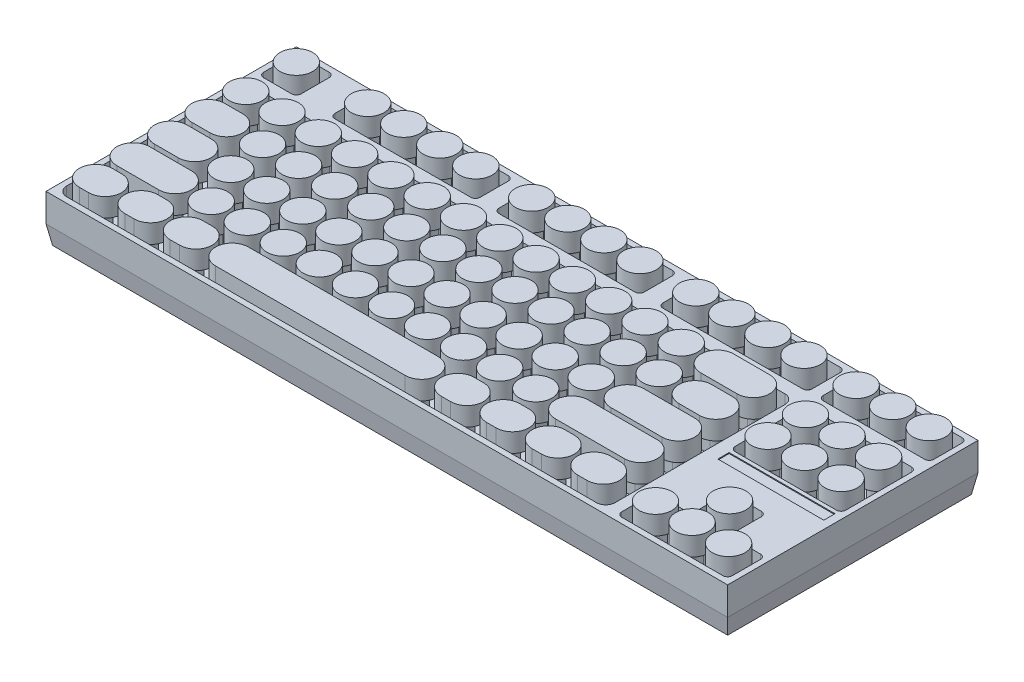
from build123d import *

# Parameters (mm, degrees)
SKETCH1_W            = 360
SKETCH1_H            = 130
BOSS_EXTRUDE1_DEPTH  = 10
DRAFT1_ANGLE         = 10
SKETCH2_W            = 363.526539614
SKETCH2_H            = 133.526539614
BOSS_EXTRUDE2_DEPTH  = 15
SKETCH3_R            = 4.5
BOSS_EXTRUDE3_DEPTH  = 15
BOSS_EXTRUDE5_START  = -4
SKETCH4_R            = 8.75
BOSS_EXTRUDE5_DEPTH  = 10
SKETCH5_W            = 56.5
SKETCH5_H            = 6
CUT_EXTRUDE1_DEPTH   = 0.5
SKETCH6_W            = 20
SKETCH6_H            = 20
CUT_EXTRUDE2_DEPTH   = 3
BOSS_EXTRUDE6_DEPTH  = 1
CUT_EXTRUDE3_DEPTH   = 20
CUT_EXTRUDE4_START   = -270
CUT_EXTRUDE4_DEPTH   = 20
BOSS_EXTRUDE7_DEPTH  = 20
BOSS_EXTRUDE8_START  = -290
BOSS_EXTRUDE8_DEPTH  = 20
BOSS_EXTRUDE12_DEPTH = 20
BOSS_EXTRUDE13_START = -290
BOSS_EXTRUDE13_DEPTH = 20


with BuildPart() as part:
    # Sketch1 → Boss-Extrude1 (new body)
    with BuildSketch(Plane(origin=(0, 0, 0), x_dir=(1, 0, 0), z_dir=(0, 1, 0))):
        Rectangle(SKETCH1_W, SKETCH1_H)
    extrude(amount=BOSS_EXTRUDE1_DEPTH)

    # Draft1
    draft1_faces = [part.faces().sort_by_distance(p)[0] for p in [
        (180, 5, 0),
        (0, 5, -65),
        (-180, 5, 0),
        (0, 5, 65),
    ]]
    draft(draft1_faces, Plane(origin=(0, 0, 0), x_dir=(0, 0, -1), z_dir=(0, -1, 0)), DRAFT1_ANGLE)

    # Sketch2 → Boss-Extrude2 (add)
    with BuildSketch(Plane(origin=(0, 10, 0), x_dir=(1, 0, 0), z_dir=(0, 1, 0))):
        Rectangle(SKETCH2_W, SKETCH2_H)
        with BuildLine():
            Line((111.263269807, 63.763269807), (36.766730193, 63.763269807))
            ThreePointArc((36.766730193, 63.763269807), (34.99896324, 63.03103676), (34.266730193, 61.263269807))
            Line((34.266730193, 61.263269807), (34.266730193, 46.263269807))
            ThreePointArc((34.266730193, 46.263269807), (34.99896324, 44.495502854), (36.766730193, 43.763269807))
            Line((36.766730193, 43.763269807), (111.263269807, 43.763269807))
            ThreePointArc((111.263269807, 43.763269807), (113.03103676, 44.495502854), (113.763269807, 46.263269807))
            Line((113.763269807, 46.263269807), (113.763269807, 61.263269807))
            ThreePointArc((113.763269807, 61.263269807), (113.03103676, 63.03103676), (111.263269807, 63.763269807))
        make_face(mode=Mode.SUBTRACT)
        with BuildLine():
            Line((176.263269807, 63.763269807), (122.263269807, 63.763269807))
            ThreePointArc((122.263269807, 63.763269807), (120.495502854, 63.03103676), (119.763269807, 61.263269807))
            Line((119.763269807, 61.263269807), (119.763269807, 46.263269807))
            ThreePointArc((119.763269807, 46.263269807), (120.495502854, 44.495502854), (122.263269807, 43.763269807))
            Line((122.263269807, 43.763269807), (176.263269807, 43.763269807))
            ThreePointArc((176.263269807, 43.763269807), (178.03103676, 44.495502854), (178.763269807, 46.263269807))
            Line((178.763269807, 46.263269807), (178.763269807, 61.263269807))
            ThreePointArc((178.763269807, 61.263269807), (178.03103676, 63.03103676), (176.263269807, 63.763269807))
        make_face(mode=Mode.SUBTRACT)
        with BuildLine():
            Line((178.763269807, -46.263269807), (178.763269807, -61.263269807))
            ThreePointArc((178.763269807, -61.263269807), (178.03103676, -63.03103676), (176.263269807, -63.763269807))
            Line((176.263269807, -63.763269807), (122.263269807, -63.763269807))
            ThreePointArc((122.263269807, -63.763269807), (120.495502854, -63.03103676), (119.763269807, -61.263269807))
            Line((119.763269807, -61.263269807), (119.763269807, -46.263269807))
            ThreePointArc((119.763269807, -46.263269807), (120.495502854, -44.495502854), (122.263269807, -43.763269807))
            Line((122.263269807, -43.763269807), (136.763269807, -43.763269807))
            ThreePointArc((136.763269807, -43.763269807), (138.53103676, -43.03103676), (139.263269807, -41.263269807))
            Line((139.263269807, -41.263269807), (139.263269807, -26.263269807))
            ThreePointArc((139.263269807, -26.263269807), (139.995502854, -24.495502854), (141.763269807, -23.763269807))
            Line((141.763269807, -23.763269807), (156.763269807, -23.763269807))
            ThreePointArc((156.763269807, -23.763269807), (158.53103676, -24.495502854), (159.263269807, -26.263269807))
            Line((159.263269807, -26.263269807), (159.263269807, -41.263269807))
            ThreePointArc((159.263269807, -41.263269807), (159.995502854, -43.03103676), (161.763269807, -43.763269807))
            Line((161.763269807, -43.763269807), (176.263269807, -43.763269807))
            ThreePointArc((176.263269807, -43.763269807), (178.03103676, -44.495502854), (178.763269807, -46.263269807))
        make_face(mode=Mode.SUBTRACT)
        with BuildLine():
            Line((-178.763269807, 31.763269807), (-178.763269807, -58.763269807))
            ThreePointArc((-178.763269807, -58.763269807), (-177.298803713, -62.298803713), (-173.763269807, -63.763269807))
            Line((-173.763269807, -63.763269807), (108.763269807, -63.763269807))
            ThreePointArc((108.763269807, -63.763269807), (112.298803713, -62.298803713), (113.763269807, -58.763269807))
            Line((113.763269807, -58.763269807), (113.763269807, 31.763269807))
            ThreePointArc((113.763269807, 31.763269807), (112.298803713, 35.298803713), (108.763269807, 36.763269807))
            Line((108.763269807, 36.763269807), (-173.763269807, 36.763269807))
            ThreePointArc((-173.763269807, 36.763269807), (-177.298803713, 35.298803713), (-178.763269807, 31.763269807))
        make_face(mode=Mode.SUBTRACT)
        with BuildLine():
            Line((-161.263269807, 63.763269807), (-176.263269807, 63.763269807))
            ThreePointArc((-176.263269807, 63.763269807), (-178.03103676, 63.03103676), (-178.763269807, 61.263269807))
            Line((-178.763269807, 61.263269807), (-178.763269807, 46.263269807))
            ThreePointArc((-178.763269807, 46.263269807), (-178.03103676, 44.495502854), (-176.263269807, 43.763269807))
            Line((-176.263269807, 43.763269807), (-161.263269807, 43.763269807))
            ThreePointArc((-161.263269807, 43.763269807), (-159.495502854, 44.495502854), (-158.763269807, 46.263269807))
            Line((-158.763269807, 46.263269807), (-158.763269807, 61.263269807))
            ThreePointArc((-158.763269807, 61.263269807), (-159.495502854, 63.03103676), (-161.263269807, 63.763269807))
        make_face(mode=Mode.SUBTRACT)
        with BuildLine():
            Line((-65.733269807, 63.763269807), (-138.233269807, 63.763269807))
            ThreePointArc((-138.233269807, 63.763269807), (-140.00103676, 63.03103676), (-140.733269807, 61.263269807))
            Line((-140.733269807, 61.263269807), (-140.733269807, 46.263269807))
            ThreePointArc((-140.733269807, 46.263269807), (-140.00103676, 44.495502854), (-138.233269807, 43.763269807))
            Line((-138.233269807, 43.763269807), (-65.733269807, 43.763269807))
            ThreePointArc((-65.733269807, 43.763269807), (-63.965502854, 44.495502854), (-63.233269807, 46.263269807))
            Line((-63.233269807, 46.263269807), (-63.233269807, 61.263269807))
            ThreePointArc((-63.233269807, 61.263269807), (-63.965502854, 63.03103676), (-65.733269807, 63.763269807))
        make_face(mode=Mode.SUBTRACT)
        with BuildLine():
            Line((21.766730193, 63.763269807), (-50.733269807, 63.763269807))
            ThreePointArc((-50.733269807, 63.763269807), (-52.50103676, 63.03103676), (-53.233269807, 61.263269807))
            Line((-53.233269807, 61.263269807), (-53.233269807, 46.263269807))
            ThreePointArc((-53.233269807, 46.263269807), (-52.50103676, 44.495502854), (-50.733269807, 43.763269807))
            Line((-50.733269807, 43.763269807), (21.766730193, 43.763269807))
            ThreePointArc((21.766730193, 43.763269807), (23.534497146, 44.495502854), (24.266730193, 46.263269807))
            Line((24.266730193, 46.263269807), (24.266730193, 61.263269807))
            ThreePointArc((24.266730193, 61.263269807), (23.534497146, 63.03103676), (21.766730193, 63.763269807))
        make_face(mode=Mode.SUBTRACT)
        with BuildLine():
            Line((176.263269807, 36.763269807), (122.263269807, 36.763269807))
            ThreePointArc((122.263269807, 36.763269807), (120.495502854, 36.03103676), (119.763269807, 34.263269807))
            Line((119.763269807, 34.263269807), (119.763269807, -0.736730193))
            ThreePointArc((119.763269807, -0.736730193), (120.495502854, -2.504497146), (122.263269807, -3.236730193))
            Line((122.263269807, -3.236730193), (176.263269807, -3.236730193))
            ThreePointArc((176.263269807, -3.236730193), (178.03103676, -2.504497146), (178.763269807, -0.736730193))
            Line((178.763269807, -0.736730193), (178.763269807, 34.263269807))
            ThreePointArc((178.763269807, 34.263269807), (178.03103676, 36.03103676), (176.263269807, 36.763269807))
        make_face(mode=Mode.SUBTRACT)
    extrude(amount=BOSS_EXTRUDE2_DEPTH)

    # Sketch3 → Boss-Extrude3 (add)
    with BuildSketch(Plane(origin=(0, 10, 0), x_dir=(1, 0, 0), z_dir=(0, 1, 0))):
        with Locations((-168.763269807, 53.763269807)):
            Circle(SKETCH3_R)
        with Locations((-130.733269807, 53.763269807)):
            Circle(SKETCH3_R)
        with Locations((-111.508269807, 53.763269807)):
            Circle(SKETCH3_R)
        with Locations((-92.458269807, 53.763269807)):
            Circle(SKETCH3_R)
        with Locations((-73.233269807, 53.763269807)):
            Circle(SKETCH3_R)
        with Locations((-43.233269807, 53.763269807)):
            Circle(SKETCH3_R)
        with Locations((44.266730193, 53.763269807)):
            Circle(SKETCH3_R)
        with Locations((129.763269807, 53.763269807)):
            Circle(SKETCH3_R)
        with Locations((-24.003269807, 53.763269807)):
            Circle(SKETCH3_R)
        with Locations((-4.773269807, 53.763269807)):
            Circle(SKETCH3_R)
        with Locations((14.456730193, 53.763269807)):
            Circle(SKETCH3_R)
        with Locations((63.496730193, 53.763269807)):
            Circle(SKETCH3_R)
        with Locations((82.726730193, 53.763269807)):
            Circle(SKETCH3_R)
        with Locations((101.956730193, 53.763269807)):
            Circle(SKETCH3_R)
        with Locations((168.763269807, 53.763269807)):
            Circle(SKETCH3_R)
        with Locations((149.263269807, 53.763269807)):
            Circle(SKETCH3_R)
        with Locations((129.763269807, 26.763269807)):
            Circle(SKETCH3_R)
        with Locations((149.263269807, 26.763269807)):
            Circle(SKETCH3_R)
        with Locations((168.763269807, 26.763269807)):
            Circle(SKETCH3_R)
        with Locations((168.763269807, 6.763269807)):
            Circle(SKETCH3_R)
        with Locations((149.263269807, 6.763269807)):
            Circle(SKETCH3_R)
        with Locations((129.763269807, 6.763269807)):
            Circle(SKETCH3_R)
        with Locations((63.496730193, 26.763269807)):
            Circle(SKETCH3_R)
        with Locations((44.141730193, 26.763269807)):
            Circle(SKETCH3_R)
        with Locations((24.786730193, 26.763269807)):
            Circle(SKETCH3_R)
        with Locations((5.431730193, 26.763269807)):
            Circle(SKETCH3_R)
        with Locations((-13.923269807, 26.763269807)):
            Circle(SKETCH3_R)
        with Locations((-33.278269807, 26.763269807)):
            Circle(SKETCH3_R)
        with Locations((-52.633269807, 26.763269807)):
            Circle(SKETCH3_R)
        with Locations((-71.988269807, 26.763269807)):
            Circle(SKETCH3_R)
        with Locations((-91.343269807, 26.763269807)):
            Circle(SKETCH3_R)
        with Locations((-110.698269807, 26.763269807)):
            Circle(SKETCH3_R)
        with Locations((-130.053269807, 26.763269807)):
            Circle(SKETCH3_R)
        with Locations((-149.408269807, 26.763269807)):
            Circle(SKETCH3_R)
        with Locations((-168.763269807, 26.763269807)):
            Circle(SKETCH3_R)
        with Locations((129.763269807, -53.236730193)):
            Circle(SKETCH3_R)
        with Locations((149.263269807, -53.236730193)):
            Circle(SKETCH3_R)
        with Locations((168.763269807, -53.236730193)):
            Circle(SKETCH3_R)
        with Locations((149.263269807, -33.236730193)):
            Circle(SKETCH3_R)
        with Locations((-139.793269807, 6.763269807)):
            Circle(SKETCH3_R)
        with Locations((-120.563269807, 6.763269807)):
            Circle(SKETCH3_R)
        with Locations((-101.333269807, 6.763269807)):
            Circle(SKETCH3_R)
        with Locations((-82.103269807, 6.763269807)):
            Circle(SKETCH3_R)
        with Locations((-62.873269807, 6.763269807)):
            Circle(SKETCH3_R)
        with Locations((-43.643269807, 6.763269807)):
            Circle(SKETCH3_R)
        with Locations((-24.413269807, 6.763269807)):
            Circle(SKETCH3_R)
        with Locations((-5.183269807, 6.763269807)):
            Circle(SKETCH3_R)
        with Locations((14.046730193, 6.763269807)):
            Circle(SKETCH3_R)
        with Locations((33.276730193, 6.763269807)):
            Circle(SKETCH3_R)
        with Locations((52.506730193, 6.763269807)):
            Circle(SKETCH3_R)
        with Locations((71.736730193, 6.763269807)):
            Circle(SKETCH3_R)
        with Locations((-136.793269807, -13.236730193)):
            Circle(SKETCH3_R)
        with Locations((-117.563269807, -13.236730193)):
            Circle(SKETCH3_R)
        with Locations((-98.333269807, -13.236730193)):
            Circle(SKETCH3_R)
        with Locations((-79.103269807, -13.236730193)):
            Circle(SKETCH3_R)
        with Locations((-59.873269807, -13.236730193)):
            Circle(SKETCH3_R)
        with Locations((-40.643269807, -13.236730193)):
            Circle(SKETCH3_R)
        with Locations((-21.413269807, -13.236730193)):
            Circle(SKETCH3_R)
        with Locations((-2.183269807, -13.236730193)):
            Circle(SKETCH3_R)
        with Locations((17.046730193, -13.236730193)):
            Circle(SKETCH3_R)
        with Locations((36.276730193, -13.236730193)):
            Circle(SKETCH3_R)
        with Locations((55.506730193, -13.236730193)):
            Circle(SKETCH3_R)
        with Locations((-127.178269807, -33.236730193)):
            Circle(SKETCH3_R)
        with Locations((-107.948269807, -33.236730193)):
            Circle(SKETCH3_R)
        with Locations((-88.718269807, -33.236730193)):
            Circle(SKETCH3_R)
        with Locations((-69.488269807, -33.236730193)):
            Circle(SKETCH3_R)
        with Locations((-50.258269807, -33.236730193)):
            Circle(SKETCH3_R)
        with Locations((-31.028269807, -33.236730193)):
            Circle(SKETCH3_R)
        with Locations((-11.798269807, -33.236730193)):
            Circle(SKETCH3_R)
        with Locations((7.431730193, -33.236730193)):
            Circle(SKETCH3_R)
        with Locations((26.661730193, -33.236730193)):
            Circle(SKETCH3_R)
        with Locations((45.891730193, -33.236730193)):
            Circle(SKETCH3_R)
        with BuildLine():
            Line((-168.763269807, 9.763269807), (-159.023269807, 9.763269807))
            ThreePointArc((-159.023269807, 9.763269807), (-156.023269807, 6.763269807), (-159.023269807, 3.763269807))
            Line((-159.023269807, 3.763269807), (-168.763269807, 3.763269807))
            ThreePointArc((-168.763269807, 3.763269807), (-171.763269807, 6.763269807), (-168.763269807, 9.763269807))
        make_face()
        with BuildLine():
            Line((-168.763269807, -10.236730193), (-156.023269807, -10.236730193))
            ThreePointArc((-156.023269807, -10.236730193), (-153.023269807, -13.236730193), (-156.023269807, -16.236730193))
            Line((-156.023269807, -16.236730193), (-168.763269807, -16.236730193))
            ThreePointArc((-168.763269807, -16.236730193), (-171.763269807, -13.236730193), (-168.763269807, -10.236730193))
        make_face()
        with BuildLine():
            Line((-168.763269807, -30.236730193), (-146.408269807, -30.236730193))
            ThreePointArc((-146.408269807, -30.236730193), (-143.408269807, -33.236730193), (-146.408269807, -36.236730193))
            Line((-146.408269807, -36.236730193), (-168.763269807, -36.236730193))
            ThreePointArc((-168.763269807, -36.236730193), (-171.763269807, -33.236730193), (-168.763269807, -30.236730193))
        make_face()
        with BuildLine():
            Line((82.726730193, 29.763269807), (101.956730193, 29.763269807))
            ThreePointArc((101.956730193, 29.763269807), (104.956730193, 26.763269807), (101.956730193, 23.763269807))
            Line((101.956730193, 23.763269807), (82.726730193, 23.763269807))
            ThreePointArc((82.726730193, 23.763269807), (79.726730193, 26.763269807), (82.726730193, 29.763269807))
        make_face()
        with BuildLine():
            Line((90.966730193, 9.763269807), (101.956730193, 9.763269807))
            ThreePointArc((101.956730193, 9.763269807), (104.956730193, 6.763269807), (101.956730193, 3.763269807))
            Line((101.956730193, 3.763269807), (90.966730193, 3.763269807))
            ThreePointArc((90.966730193, 3.763269807), (87.966730193, 6.763269807), (90.966730193, 9.763269807))
        make_face()
        with BuildLine():
            Line((74.736730193, -10.236730193), (101.956730193, -10.236730193))
            ThreePointArc((101.956730193, -10.236730193), (104.956730193, -13.236730193), (101.956730193, -16.236730193))
            Line((101.956730193, -16.236730193), (74.736730193, -16.236730193))
            ThreePointArc((74.736730193, -16.236730193), (71.736730193, -13.236730193), (74.736730193, -10.236730193))
        make_face()
        with BuildLine():
            Line((65.121730193, -30.236730193), (101.956730193, -30.236730193))
            ThreePointArc((101.956730193, -30.236730193), (104.956730193, -33.236730193), (101.956730193, -36.236730193))
            Line((101.956730193, -36.236730193), (65.121730193, -36.236730193))
            ThreePointArc((65.121730193, -36.236730193), (62.121730193, -33.236730193), (65.121730193, -30.236730193))
        make_face()
        with BuildLine():
            Line((-168.763269807, -50.236730193), (-163.763269807, -50.236730193))
            ThreePointArc((-163.763269807, -50.236730193), (-160.763269807, -53.236730193), (-163.763269807, -56.236730193))
            Line((-163.763269807, -56.236730193), (-168.763269807, -56.236730193))
            ThreePointArc((-168.763269807, -56.236730193), (-171.763269807, -53.236730193), (-168.763269807, -50.236730193))
        make_face()
        with BuildLine():
            Line((-144.533269807, -50.236730193), (-139.533269807, -50.236730193))
            ThreePointArc((-139.533269807, -50.236730193), (-136.533269807, -53.236730193), (-139.533269807, -56.236730193))
            Line((-139.533269807, -56.236730193), (-144.533269807, -56.236730193))
            ThreePointArc((-144.533269807, -56.236730193), (-147.533269807, -53.236730193), (-144.533269807, -50.236730193))
        make_face()
        with BuildLine():
            Line((-120.303269807, -50.236730193), (-115.303269807, -50.236730193))
            ThreePointArc((-115.303269807, -50.236730193), (-112.303269807, -53.236730193), (-115.303269807, -56.236730193))
            Line((-115.303269807, -56.236730193), (-120.303269807, -56.236730193))
            ThreePointArc((-120.303269807, -56.236730193), (-123.303269807, -53.236730193), (-120.303269807, -50.236730193))
        make_face()
        with BuildLine():
            Line((96.956730193, -50.236730193), (101.956730193, -50.236730193))
            ThreePointArc((101.956730193, -50.236730193), (104.956730193, -53.236730193), (101.956730193, -56.236730193))
            Line((101.956730193, -56.236730193), (96.956730193, -56.236730193))
            ThreePointArc((96.956730193, -56.236730193), (93.956730193, -53.236730193), (96.956730193, -50.236730193))
        make_face()
        with BuildLine():
            Line((72.726730193, -50.236730193), (77.726730193, -50.236730193))
            ThreePointArc((77.726730193, -50.236730193), (80.726730193, -53.236730193), (77.726730193, -56.236730193))
            Line((77.726730193, -56.236730193), (72.726730193, -56.236730193))
            ThreePointArc((72.726730193, -56.236730193), (69.726730193, -53.236730193), (72.726730193, -50.236730193))
        make_face()
        with BuildLine():
            Line((48.496730193, -50.236730193), (53.496730193, -50.236730193))
            ThreePointArc((53.496730193, -50.236730193), (56.496730193, -53.236730193), (53.496730193, -56.236730193))
            Line((53.496730193, -56.236730193), (48.496730193, -56.236730193))
            ThreePointArc((48.496730193, -56.236730193), (45.496730193, -53.236730193), (48.496730193, -50.236730193))
        make_face()
        with BuildLine():
            Line((24.266730193, -50.236730193), (29.266730193, -50.236730193))
            ThreePointArc((29.266730193, -50.236730193), (32.266730193, -53.236730193), (29.266730193, -56.236730193))
            Line((29.266730193, -56.236730193), (24.266730193, -56.236730193))
            ThreePointArc((24.266730193, -56.236730193), (21.266730193, -53.236730193), (24.266730193, -50.236730193))
        make_face()
        with BuildLine():
            Line((-96.073269807, -50.236730193), (5.036730193, -50.236730193))
            ThreePointArc((5.036730193, -50.236730193), (8.036730193, -53.236730193), (5.036730193, -56.236730193))
            Line((5.036730193, -56.236730193), (-96.073269807, -56.236730193))
            ThreePointArc((-96.073269807, -56.236730193), (-99.073269807, -53.236730193), (-96.073269807, -50.236730193))
        make_face()
    extrude(amount=BOSS_EXTRUDE3_DEPTH)

    # Sketch4 → Boss-Extrude5 (add)
    with BuildSketch(Plane(origin=(0, 25, 0), x_dir=(1, 0, 0), z_dir=(0, 1, 0)).offset(BOSS_EXTRUDE5_START)):
        with Locations((-168.763269807, 53.763269807)):
            Circle(SKETCH4_R)
        with Locations((-130.733269807, 53.763269807)):
            Circle(SKETCH4_R)
        with Locations((-111.508269807, 53.763269807)):
            Circle(SKETCH4_R)
        with Locations((-92.283269807, 53.763269807)):
            Circle(SKETCH4_R)
        with Locations((-73.058269807, 53.763269807)):
            Circle(SKETCH4_R)
        with Locations((-43.233269807, 53.763269807)):
            Circle(SKETCH4_R)
        with Locations((-24.003269807, 53.763269807)):
            Circle(SKETCH4_R)
        with Locations((-4.773269807, 53.763269807)):
            Circle(SKETCH4_R)
        with Locations((14.456730193, 53.763269807)):
            Circle(SKETCH4_R)
        with Locations((44.266730193, 53.763269807)):
            Circle(SKETCH4_R)
        with Locations((63.496730193, 53.763269807)):
            Circle(SKETCH4_R)
        with Locations((82.726730193, 53.763269807)):
            Circle(SKETCH4_R)
        with Locations((101.956730193, 53.763269807)):
            Circle(SKETCH4_R)
        with Locations((129.763269807, 53.763269807)):
            Circle(SKETCH4_R)
        with Locations((149.263269807, 53.763269807)):
            Circle(SKETCH4_R)
        with Locations((168.763269807, 53.763269807)):
            Circle(SKETCH4_R)
        with Locations((63.496730193, 26.763269807)):
            Circle(SKETCH4_R)
        with Locations((44.141730193, 26.763269807)):
            Circle(SKETCH4_R)
        with Locations((24.786730193, 26.763269807)):
            Circle(SKETCH4_R)
        with Locations((5.431730193, 26.763269807)):
            Circle(SKETCH4_R)
        with Locations((-13.923269807, 26.763269807)):
            Circle(SKETCH4_R)
        with Locations((-33.278269807, 26.763269807)):
            Circle(SKETCH4_R)
        with Locations((-52.633269807, 26.763269807)):
            Circle(SKETCH4_R)
        with Locations((-71.988269807, 26.763269807)):
            Circle(SKETCH4_R)
        with Locations((-91.343269807, 26.763269807)):
            Circle(SKETCH4_R)
        with Locations((-110.698269807, 26.763269807)):
            Circle(SKETCH4_R)
        with Locations((-130.053269807, 26.763269807)):
            Circle(SKETCH4_R)
        with Locations((-149.408269807, 26.763269807)):
            Circle(SKETCH4_R)
        with Locations((-168.763269807, 26.763269807)):
            Circle(SKETCH4_R)
        with Locations((71.736730193, 6.763269807)):
            Circle(SKETCH4_R)
        with Locations((52.506730193, 6.763269807)):
            Circle(SKETCH4_R)
        with Locations((33.276730193, 6.763269807)):
            Circle(SKETCH4_R)
        with Locations((14.046730193, 6.763269807)):
            Circle(SKETCH4_R)
        with Locations((-5.183269807, 6.763269807)):
            Circle(SKETCH4_R)
        with Locations((-24.413269807, 6.763269807)):
            Circle(SKETCH4_R)
        with Locations((-43.643269807, 6.763269807)):
            Circle(SKETCH4_R)
        with Locations((-62.873269807, 6.763269807)):
            Circle(SKETCH4_R)
        with Locations((-82.103269807, 6.763269807)):
            Circle(SKETCH4_R)
        with Locations((-101.333269807, 6.763269807)):
            Circle(SKETCH4_R)
        with Locations((-120.563269807, 6.763269807)):
            Circle(SKETCH4_R)
        with Locations((-139.793269807, 6.763269807)):
            Circle(SKETCH4_R)
        with Locations((129.763269807, 26.763269807)):
            Circle(SKETCH4_R)
        with Locations((129.763269807, 6.763269807)):
            Circle(SKETCH4_R)
        with Locations((168.763269807, 26.763269807)):
            Circle(SKETCH4_R)
        with Locations((168.763269807, 6.763269807)):
            Circle(SKETCH4_R)
        with Locations((149.263269807, 26.763269807)):
            Circle(SKETCH4_R)
        with Locations((149.263269807, 6.763269807)):
            Circle(SKETCH4_R)
        with Locations((129.763269807, -53.236730193)):
            Circle(SKETCH4_R)
        with Locations((149.263269807, -33.236730193)):
            Circle(SKETCH4_R)
        with Locations((149.263269807, -53.236730193)):
            Circle(SKETCH4_R)
        with Locations((168.763269807, -53.236730193)):
            Circle(SKETCH4_R)
        with Locations((-136.793269807, -13.236730193)):
            Circle(SKETCH4_R)
        with Locations((-117.563269807, -13.236730193)):
            Circle(SKETCH4_R)
        with Locations((-98.333269807, -13.236730193)):
            Circle(SKETCH4_R)
        with Locations((-79.103269807, -13.236730193)):
            Circle(SKETCH4_R)
        with Locations((-59.873269807, -13.236730193)):
            Circle(SKETCH4_R)
        with Locations((-40.643269807, -13.236730193)):
            Circle(SKETCH4_R)
        with Locations((-21.413269807, -13.236730193)):
            Circle(SKETCH4_R)
        with Locations((-2.183269807, -13.236730193)):
            Circle(SKETCH4_R)
        with Locations((17.046730193, -13.236730193)):
            Circle(SKETCH4_R)
        with Locations((36.276730193, -13.236730193)):
            Circle(SKETCH4_R)
        with Locations((55.506730193, -13.236730193)):
            Circle(SKETCH4_R)
        with Locations((-127.178269807, -33.236730193)):
            Circle(SKETCH4_R)
        with Locations((-107.948269807, -33.236730193)):
            Circle(SKETCH4_R)
        with Locations((-88.718269807, -33.236730193)):
            Circle(SKETCH4_R)
        with Locations((-69.488269807, -33.236730193)):
            Circle(SKETCH4_R)
        with Locations((-50.258269807, -33.236730193)):
            Circle(SKETCH4_R)
        with Locations((-31.028269807, -33.236730193)):
            Circle(SKETCH4_R)
        with Locations((-11.798269807, -33.236730193)):
            Circle(SKETCH4_R)
        with Locations((7.431730193, -33.236730193)):
            Circle(SKETCH4_R)
        with Locations((26.661730193, -33.236730193)):
            Circle(SKETCH4_R)
        with Locations((45.891730193, -33.236730193)):
            Circle(SKETCH4_R)
        with BuildLine():
            Line((-168.763269807, 15.513269807), (-159.023269807, 15.513269807))
            ThreePointArc((-159.023269807, 15.513269807), (-150.273269807, 6.763269807), (-159.023269807, -1.986730193))
            Line((-159.023269807, -1.986730193), (-168.763269807, -1.986730193))
            ThreePointArc((-168.763269807, -1.986730193), (-177.513269807, 6.763269807), (-168.763269807, 15.513269807))
        make_face()
        with BuildLine():
            Line((-168.763269807, -4.486730193), (-156.023269807, -4.486730193))
            ThreePointArc((-156.023269807, -4.486730193), (-147.273269807, -13.236730193), (-156.023269807, -21.986730193))
            Line((-156.023269807, -21.986730193), (-168.763269807, -21.986730193))
            ThreePointArc((-168.763269807, -21.986730193), (-177.513269807, -13.236730193), (-168.763269807, -4.486730193))
        make_face()
        with BuildLine():
            Line((-168.763269807, -24.486730193), (-146.408269807, -24.486730193))
            ThreePointArc((-146.408269807, -24.486730193), (-137.658269807, -33.236730193), (-146.408269807, -41.986730193))
            Line((-146.408269807, -41.986730193), (-168.763269807, -41.986730193))
            ThreePointArc((-168.763269807, -41.986730193), (-177.513269807, -33.236730193), (-168.763269807, -24.486730193))
        make_face()
        with BuildLine():
            Line((82.726730193, 35.513269807), (101.956730193, 35.513269807))
            ThreePointArc((101.956730193, 35.513269807), (110.706730193, 26.763269807), (101.956730193, 18.013269807))
            Line((101.956730193, 18.013269807), (82.726730193, 18.013269807))
            ThreePointArc((82.726730193, 18.013269807), (73.976730193, 26.763269807), (82.726730193, 35.513269807))
        make_face()
        with BuildLine():
            Line((90.966730193, 15.513269807), (101.956730193, 15.513269807))
            ThreePointArc((101.956730193, 15.513269807), (110.706730193, 6.763269807), (101.956730193, -1.986730193))
            Line((101.956730193, -1.986730193), (90.966730193, -1.986730193))
            ThreePointArc((90.966730193, -1.986730193), (82.216730193, 6.763269807), (90.966730193, 15.513269807))
        make_face()
        with BuildLine():
            Line((74.736730193, -4.486730193), (101.956730193, -4.486730193))
            ThreePointArc((101.956730193, -4.486730193), (110.706730193, -13.236730193), (101.956730193, -21.986730193))
            Line((101.956730193, -21.986730193), (74.736730193, -21.986730193))
            ThreePointArc((74.736730193, -21.986730193), (65.986730193, -13.236730193), (74.736730193, -4.486730193))
        make_face()
        with BuildLine():
            Line((65.121730193, -24.486730193), (101.956730193, -24.486730193))
            ThreePointArc((101.956730193, -24.486730193), (110.706730193, -33.236730193), (101.956730193, -41.986730193))
            Line((101.956730193, -41.986730193), (65.121730193, -41.986730193))
            ThreePointArc((65.121730193, -41.986730193), (56.371730193, -33.236730193), (65.121730193, -24.486730193))
        make_face()
        with BuildLine():
            Line((-168.763269807, -44.486730193), (-163.763269807, -44.486730193))
            ThreePointArc((-163.763269807, -44.486730193), (-155.013269807, -53.236730193), (-163.763269807, -61.986730193))
            Line((-163.763269807, -61.986730193), (-168.763269807, -61.986730193))
            ThreePointArc((-168.763269807, -61.986730193), (-177.513269807, -53.236730193), (-168.763269807, -44.486730193))
        make_face()
        with BuildLine():
            Line((-144.533269807, -61.986730193), (-139.533269807, -61.986730193))
            ThreePointArc((-139.533269807, -61.986730193), (-130.783269807, -53.236730193), (-139.533269807, -44.486730193))
            Line((-139.533269807, -44.486730193), (-144.533269807, -44.486730193))
            ThreePointArc((-144.533269807, -44.486730193), (-153.283269807, -53.236730193), (-144.533269807, -61.986730193))
        make_face()
        with BuildLine():
            Line((-120.303269807, -61.986730193), (-115.303269807, -61.986730193))
            ThreePointArc((-115.303269807, -61.986730193), (-106.553269807, -53.236730193), (-115.303269807, -44.486730193))
            Line((-115.303269807, -44.486730193), (-120.303269807, -44.486730193))
            ThreePointArc((-120.303269807, -44.486730193), (-129.053269807, -53.236730193), (-120.303269807, -61.986730193))
        make_face()
        with BuildLine():
            Line((96.956730193, -61.986730193), (101.956730193, -61.986730193))
            ThreePointArc((101.956730193, -61.986730193), (110.706730193, -53.236730193), (101.956730193, -44.486730193))
            Line((101.956730193, -44.486730193), (96.956730193, -44.486730193))
            ThreePointArc((96.956730193, -44.486730193), (88.206730193, -53.236730193), (96.956730193, -61.986730193))
        make_face()
        with BuildLine():
            Line((72.726730193, -44.486730193), (77.726730193, -44.486730193))
            ThreePointArc((77.726730193, -44.486730193), (86.476730193, -53.236730193), (77.726730193, -61.986730193))
            Line((77.726730193, -61.986730193), (72.726730193, -61.986730193))
            ThreePointArc((72.726730193, -61.986730193), (63.976730193, -53.236730193), (72.726730193, -44.486730193))
        make_face()
        with BuildLine():
            Line((48.496730193, -44.486730193), (53.496730193, -44.486730193))
            ThreePointArc((53.496730193, -44.486730193), (62.246730193, -53.236730193), (53.496730193, -61.986730193))
            Line((53.496730193, -61.986730193), (48.496730193, -61.986730193))
            ThreePointArc((48.496730193, -61.986730193), (39.746730193, -53.236730193), (48.496730193, -44.486730193))
        make_face()
        with BuildLine():
            Line((24.266730193, -44.486730193), (29.266730193, -44.486730193))
            ThreePointArc((29.266730193, -44.486730193), (38.016730193, -53.236730193), (29.266730193, -61.986730193))
            Line((29.266730193, -61.986730193), (24.266730193, -61.986730193))
            ThreePointArc((24.266730193, -61.986730193), (15.516730193, -53.236730193), (24.266730193, -44.486730193))
        make_face()
        with BuildLine():
            Line((-96.073269807, -44.486730193), (5.036730193, -44.486730193))
            ThreePointArc((5.036730193, -44.486730193), (13.786730193, -53.236730193), (5.036730193, -61.986730193))
            Line((5.036730193, -61.986730193), (-96.073269807, -61.986730193))
            ThreePointArc((-96.073269807, -61.986730193), (-104.823269807, -53.236730193), (-96.073269807, -44.486730193))
        make_face()
    extrude(amount=BOSS_EXTRUDE5_DEPTH)

    # Sketch5 → Cut-Extrude1 (cut)
    with BuildSketch(Plane(origin=(0, 25, 0), x_dir=(1, 0, 0), z_dir=(0, 1, 0))):
        with Locations((149.263269807, -8.236730193)):
            Rectangle(SKETCH5_W, SKETCH5_H)
    extrude(amount=-CUT_EXTRUDE1_DEPTH, mode=Mode.SUBTRACT)

    # Sketch6 → Cut-Extrude2 (cut)
    with BuildSketch(Plane.XZ):
        with Locations((145, -25)):
            Rectangle(SKETCH6_W, SKETCH6_H)
        with Locations((-145, -25)):
            Rectangle(SKETCH6_W, SKETCH6_H)
    extrude(amount=-CUT_EXTRUDE2_DEPTH, mode=Mode.SUBTRACT)

    # Sketch7 → Boss-Extrude6 (add)
    with BuildSketch(Plane.XZ):
        with BuildLine():
            Line((-152, 58), (-138, 58))
            ThreePointArc((-138, 58), (-135, 55), (-138, 52))
            Line((-138, 52), (-152, 52))
            ThreePointArc((-152, 52), (-155, 55), (-152, 58))
        make_face()
        with BuildLine():
            Line((152, 58), (138, 58))
            ThreePointArc((138, 58), (135, 55), (138, 52))
            Line((138, 52), (152, 52))
            ThreePointArc((152, 52), (155, 55), (152, 58))
        make_face()
    extrude(amount=BOSS_EXTRUDE6_DEPTH)

    # Sketch8 → Cut-Extrude3 (cut)
    with BuildSketch(Plane(origin=(135, 0, 0), x_dir=(0, 0, -1), z_dir=(1, 0, 0))):
        with BuildLine():
            Line((35, 3), (44.171805683, -0.154817715))
            ThreePointArc((44.171805683, -0.154817715), (44.502329179, -0.710073922), (44.009173158, -1.127629159))
            Line((44.009173158, -1.127629159), (35, -1.127629159))
            Line((35, -1.127629159), (35, 3))
        make_face()
    extrude(amount=CUT_EXTRUDE3_DEPTH, mode=Mode.SUBTRACT)

    # Sketch8_2 → Cut-Extrude4 (cut)
    with BuildSketch(Plane(origin=(135, 0, 0), x_dir=(0, 0, -1), z_dir=(1, 0, 0)).offset(CUT_EXTRUDE4_START)):
        with BuildLine():
            Line((35, 3), (44.171805683, -0.154817715))
            ThreePointArc((44.171805683, -0.154817715), (44.502329179, -0.710073922), (44.009173158, -1.127629159))
            Line((44.009173158, -1.127629159), (35, -1.127629159))
            Line((35, -1.127629159), (35, 3))
        make_face()
    extrude(amount=-CUT_EXTRUDE4_DEPTH, mode=Mode.SUBTRACT)

    # Sketch9 → Boss-Extrude7 (add)
    with BuildSketch(Plane(origin=(135, 0, 0), x_dir=(0, 0, -1), z_dir=(1, 0, 0))):
        with BuildLine():
            Line((43.721713752, 0), (45.033224709, 0))
            ThreePointArc((45.033224709, 0), (44.377469231, -0.455082152), (43.721713752, 0))
        make_face()
    extrude(amount=BOSS_EXTRUDE7_DEPTH)

    # Sketch9_2 → Boss-Extrude8 (add)
    with BuildSketch(Plane(origin=(135, 0, 0), x_dir=(0, 0, -1), z_dir=(1, 0, 0)).offset(BOSS_EXTRUDE8_START)):
        with BuildLine():
            Line((43.721713752, 0), (45.033224709, 0))
            ThreePointArc((45.033224709, 0), (44.377469231, -0.455082152), (43.721713752, 0))
        make_face()
    extrude(amount=BOSS_EXTRUDE8_DEPTH)


with BuildPart() as body_2:
    # Sketch10 → Boss-Extrude12 (new body)
    with BuildSketch(Plane(origin=(135, 0, 0), x_dir=(0, 0, -1), z_dir=(1, 0, 0))):
        Polygon((40.23203472, 0.693231133), (54.611324201, -3.385731155), (54.611324201, -3.740758995), (53.60847709, -3.740758995), (40.23203472, 0), align=None)
    extrude(amount=BOSS_EXTRUDE12_DEPTH)


with BuildPart() as body_3:
    # Sketch10_3 → Boss-Extrude13 (new body)
    with BuildSketch(Plane(origin=(135, 0, 0), x_dir=(0, 0, -1), z_dir=(1, 0, 0)).offset(BOSS_EXTRUDE13_START)):
        Polygon((40.23203472, 0.693231133), (54.611324201, -3.385731155), (54.611324201, -3.740758995), (53.60847709, -3.740758995), (40.23203472, 0), align=None)
    extrude(amount=BOSS_EXTRUDE13_DEPTH)


solid = Compound([part.part, body_2.part, body_3.part])
